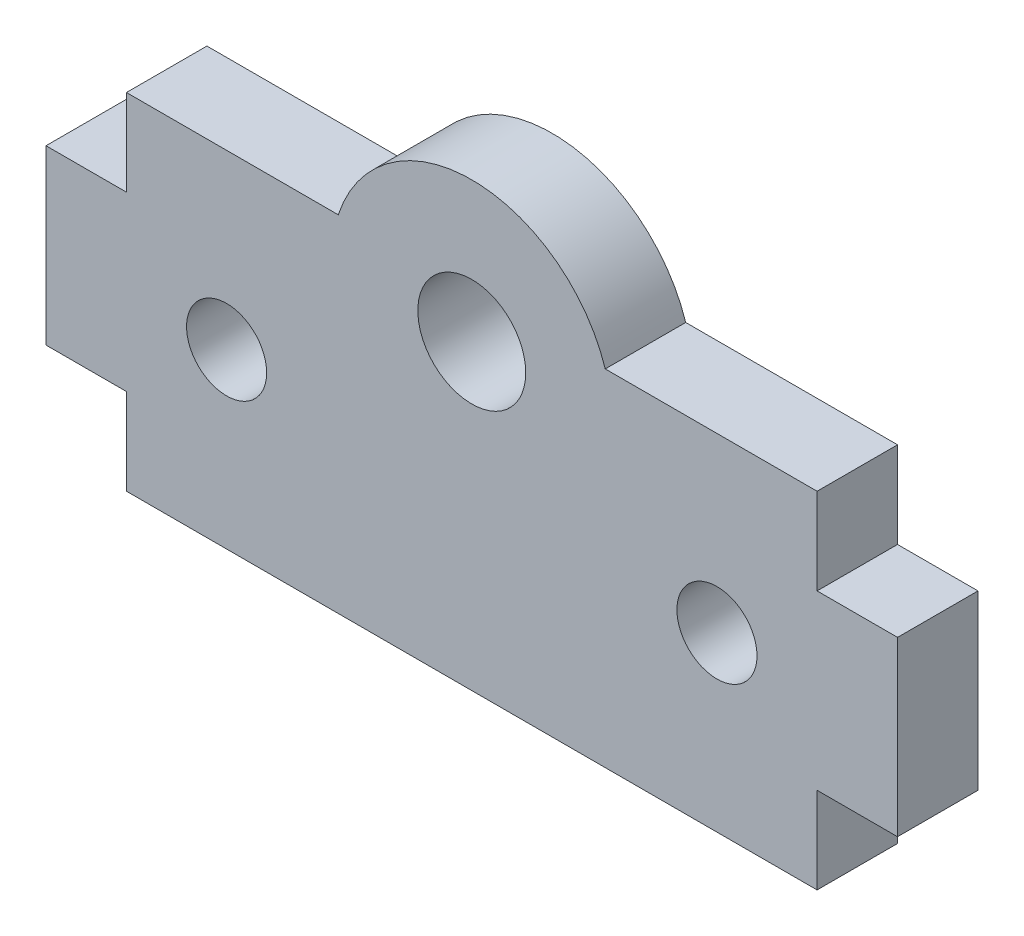
from build123d import *

# Parameters (mm, degrees)
SKETCH1_R                 = 1.984375
BOSS_EXTRUDE1_DEPTH       = 1.47955
F_4_CLEARANCE_HOLE1_D     = 2.9464
F_4_CLEARANCE_HOLE1_DEPTH = 3.302
F_4_CLEARANCE_HOLE1_TIP   = 0.885187864


with BuildPart() as part:
    # Sketch1 → Boss-Extrude1 (new body, symmetric)
    with BuildSketch(Plane.XY):
        with BuildLine():
            Line((-15.6591, -1.5875), (-15.6591, -7.9375))
            Line((-15.6591, -7.9375), (-12.7, -7.9375))
            Line((-12.7, -7.9375), (-12.7, -11.1125))
            Line((-12.7, -11.1125), (12.7, -11.1125))
            Line((12.7, -11.1125), (12.7, -7.9375))
            Line((12.7, -7.9375), (15.6591, -7.9375))
            Line((15.6591, -7.9375), (15.6591, -1.5875))
            Line((15.6591, -1.5875), (12.7, -1.5875))
            Line((12.7, -1.5875), (12.7, 1.5875))
            Line((12.7, 1.5875), (4.909072636, 1.5875))
            ThreePointArc((4.909072636, 1.5875), (0, 5.159375), (-4.909072636, 1.5875))
            Line((-4.909072636, 1.5875), (-12.7, 1.5875))
            Line((-12.7, 1.5875), (-12.7, -1.5875))
            Line((-12.7, -1.5875), (-15.6591, -1.5875))
        make_face()
        Circle(SKETCH1_R, mode=Mode.SUBTRACT)
    extrude(amount=BOSS_EXTRUDE1_DEPTH, both=True)

    # #4 Clearance Hole1
    with Locations(Plane(origin=(0.047806488, 1.573653324, 1.47955), x_dir=(1, 0, 0), z_dir=(0, 0, 1))):
        with Locations((-9.064806488, -6.336153324), (8.969193512, -6.336153324)):
            Hole(F_4_CLEARANCE_HOLE1_D / 2, depth=F_4_CLEARANCE_HOLE1_DEPTH)
            with Locations((0, 0, -(F_4_CLEARANCE_HOLE1_DEPTH + F_4_CLEARANCE_HOLE1_TIP / 2))):  # 118° drill point
                Cone(0, F_4_CLEARANCE_HOLE1_D / 2, F_4_CLEARANCE_HOLE1_TIP, mode=Mode.SUBTRACT)


solid = part.part
